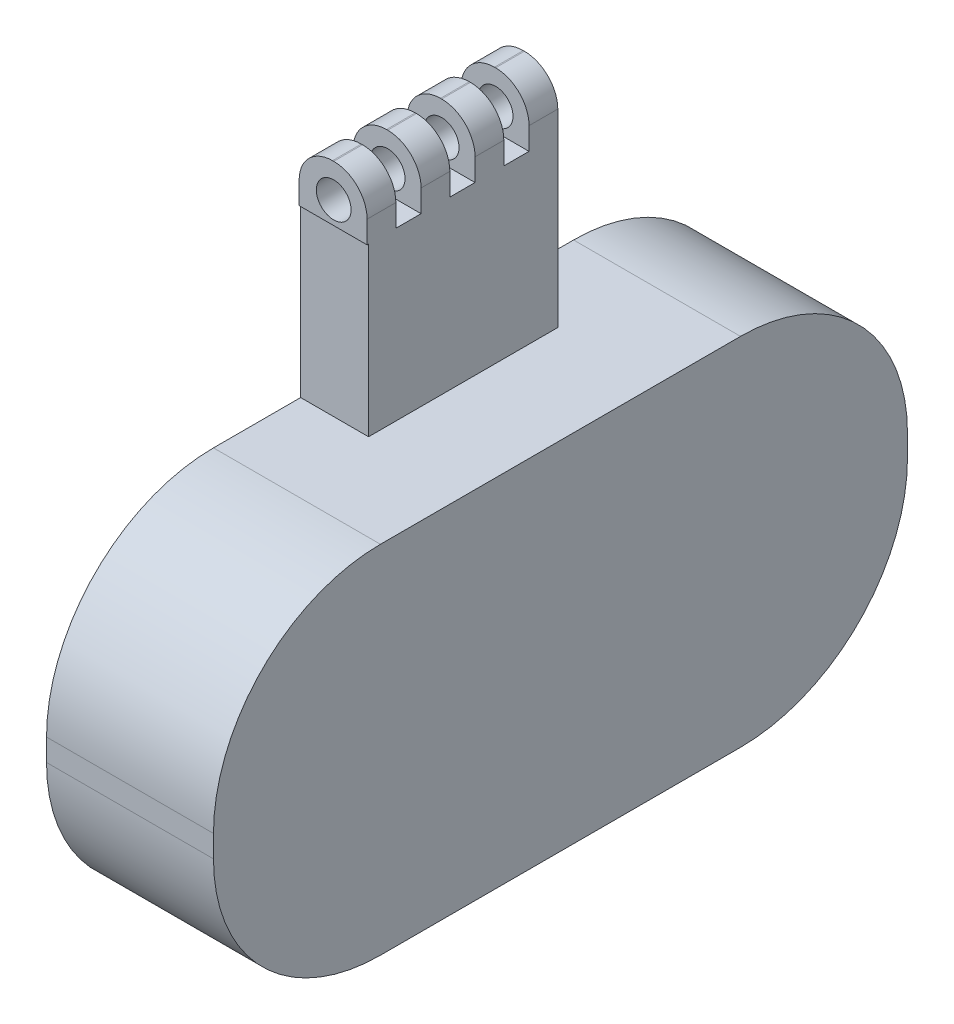
from build123d import *

# Parameters (mm, degrees)
BOSS_EXTRUDE1_DEPTH    = 30
SKETCH4_W              = 12.210528057
SKETCH4_H              = 34
BOSS_EXTRUDE3_DEPTH    = 30
SKETCH5_W              = 12.210528057
SKETCH5_H              = 5.168070784
BOSS_EXTRUDE4_DEPTH    = 10
FILLET1_R              = 6
LPATTERN1_COUNT        = 4
LPATTERN1_PITCH        = 9.7
FILLET1_OF_LPATTERN1_R = 6
SKETCH6_R              = 3.121394117
CUT_EXTRUDE1_DEPTH     = 80.311190797
SKETCH10_W             = 5.758909818
SKETCH10_H             = 38.962624233
CUT_EXTRUDE2_DEPTH     = 35
SKETCH11_W             = 3.89943497
SKETCH11_H             = 16.273957598
BOSS_EXTRUDE5_DEPTH    = 50


with BuildPart() as part:
    # Sketch1 → Boss-Extrude1 (new body)
    with BuildSketch(Plane(origin=(0, 0, 0), x_dir=(0, 0, -1), z_dir=(1, 0, 0))):
        with BuildLine():
            Line((-32.351279839, 31.978308301), (32.351279839, 31.978308301))
            ThreePointArc((32.351279839, 31.978308301), (53.564483275, 23.191511736), (62.351279839, 1.978308301))
            Line((62.351279839, 1.978308301), (62.351279839, -1.978308301))
            ThreePointArc((62.351279839, -1.978308301), (53.564483275, -23.191511736), (32.351279839, -31.978308301))
            Line((32.351279839, -31.978308301), (-32.351279839, -31.978308301))
            ThreePointArc((-32.351279839, -31.978308301), (-53.564483275, -23.191511736), (-62.351279839, -1.978308301))
            Line((-62.351279839, -1.978308301), (-62.351279839, 1.978308301))
            ThreePointArc((-62.351279839, 1.978308301), (-53.564483275, 23.191511736), (-32.351279839, 31.978308301))
        make_face()
    extrude(amount=BOSS_EXTRUDE1_DEPTH)

    # Sketch4 → Boss-Extrude3 (add)
    with BuildSketch(Plane(origin=(0, 31.978308301, 0), x_dir=(1, 0, 0), z_dir=(0, 1, 0))):
        with Locations((6.105264029, 0.308159826)):
            Rectangle(SKETCH4_W, SKETCH4_H)
    extrude(amount=BOSS_EXTRUDE3_DEPTH)

    # Sketch5 → Boss-Extrude4 (add)
    with BuildSketch(Plane(origin=(0, 61.978308301, 0), x_dir=(1, 0, 0), z_dir=(0, 1, 0))):
        with Locations((6.105264029, 14.724124434)):
            Rectangle(SKETCH5_W, SKETCH5_H)
    boss_extrude4 = extrude(amount=BOSS_EXTRUDE4_DEPTH)

    # Fillet1
    fillet1_edges = [part.edges().sort_by_distance(p)[0] for p in [
        (0, 71.978308301, -14.724124434),
        (12.210528057, 71.978308301, -14.724124434),
    ]]
    fillet(fillet1_edges, radius=FILLET1_R)

    # LPattern1: Boss-Extrude4 ×4
    with Locations(*[(0, 0, i * LPATTERN1_PITCH) for i in range(1, LPATTERN1_COUNT)]):
        add(boss_extrude4)

    # Fillet1 of LPattern1
    fillet1_of_lpattern1_edges = [part.edges().sort_by_distance(p)[0] for p in [
        (0, 71.978308301, -5.024124434),
        (12.210528057, 71.978308301, -5.024124434),
        (0, 71.978308301, 4.675875566),
        (12.210528057, 71.978308301, 4.675875566),
        (0, 71.978308301, 14.375875566),
        (12.210528057, 71.978308301, 14.375875566),
    ]]
    fillet(fillet1_of_lpattern1_edges, radius=FILLET1_OF_LPATTERN1_R)

    # Sketch6 → Cut-Extrude1 (cut, through all)
    with BuildSketch(Plane.XY.offset(16.959910958)):
        with Locations((6.210528057, 65.978308301)):
            Circle(SKETCH6_R)
    extrude(amount=-CUT_EXTRUDE1_DEPTH, mode=Mode.SUBTRACT)

    # Sketch10 → Cut-Extrude2 (cut)
    with BuildSketch(Plane.XZ.offset(31.978308301)):
        with Locations((5.551788581, -0.179965931)):
            Rectangle(SKETCH10_W, SKETCH10_H)
    extrude(amount=-CUT_EXTRUDE2_DEPTH, mode=Mode.SUBTRACT)

    # Sketch11 → Boss-Extrude5 (add)
    with BuildSketch(Plane.XZ.offset(-3.021691699)):
        with Locations((5.619023304, 0.398013913)):
            Rectangle(SKETCH11_W, SKETCH11_H)
    extrude(amount=BOSS_EXTRUDE5_DEPTH)


solid = part.part
